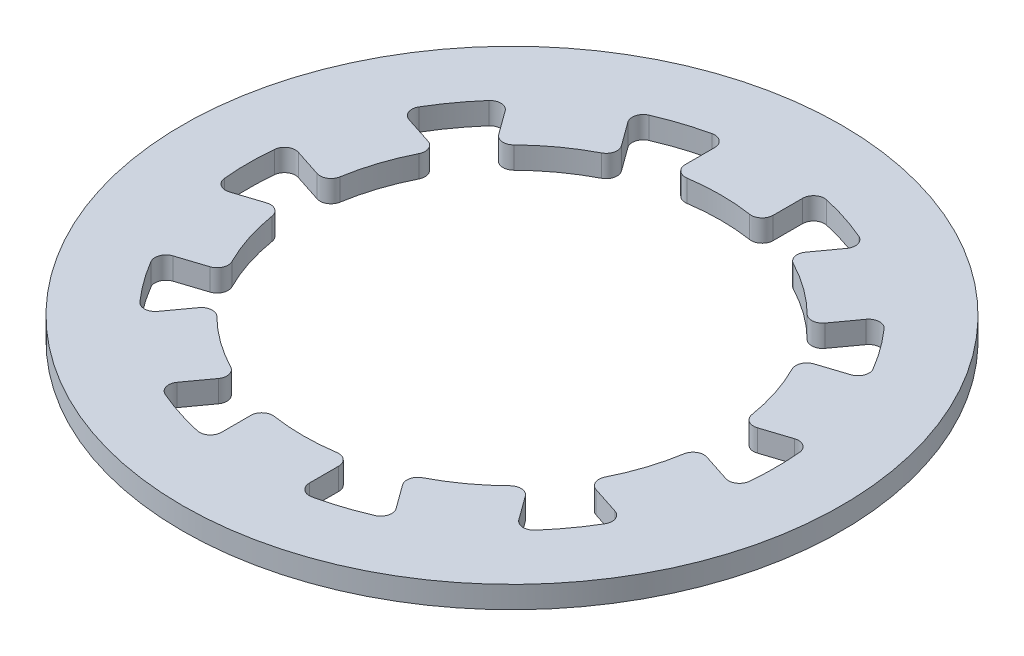
from build123d import *

# Parameters (mm, degrees)
SKETCH1_R           = 15
BOSS_EXTRUDE1_DEPTH = 1


with BuildPart() as part:
    # Sketch1 → Boss-Extrude1 (new body)
    with BuildSketch(Plane(origin=(0, 0, 0), x_dir=(1, 0, 0), z_dir=(0, 1, 0))):
        Circle(SKETCH1_R)
        with BuildLine():
            Line((-2, 11.22497216), (-2, 9.886859967))
            ThreePointArc((-2, 9.886859967), (-1.82596012, 9.507716194), (-1.425, 9.392516968))
            ThreePointArc((-1.425, 9.392516968), (0, 9.5), (1.425, 9.392516968))
            ThreePointArc((1.425, 9.392516968), (1.82596012, 9.507716194), (2, 9.886859967))
            Line((2, 9.886859967), (2, 11.22497216))
            ThreePointArc((2, 11.22497216), (2.187228379, 11.615066909), (2.608695652, 11.713014428))
            ThreePointArc((2.608695652, 11.713014428), (3.708203932, 11.412678196), (4.774258025, 11.00938056))
            ThreePointArc((4.774258025, 11.00938056), (5.057660104, 10.682407105), (4.979839104, 10.256763744))
            Line((4.979839104, 10.256763744), (4.193316491, 9.174208239))
            ThreePointArc((4.193316491, 9.174208239), (4.111262594, 8.765176409), (4.367933739, 8.436299832))
            ThreePointArc((4.367933739, 8.436299832), (5.583959897, 7.685661447), (6.673632173, 6.761111863))
            ThreePointArc((6.673632173, 6.761111863), (7.06572813, 6.618631549), (7.429384469, 6.823067229))
            Line((7.429384469, 6.823067229), (8.215907082, 7.905622735))
            ThreePointArc((8.215907082, 7.905622735), (8.596669963, 8.111165936), (8.995216257, 7.942674896))
            ThreePointArc((8.995216257, 7.942674896), (9.708203932, 7.053423028), (10.333607408, 6.100537513))
            ThreePointArc((10.333607408, 6.100537513), (10.370694331, 5.669430868), (10.05754893, 5.370820192))
            Line((10.05754893, 5.370820192), (8.784928608, 4.957320783))
            ThreePointArc((8.784928608, 4.957320783), (8.478122734, 4.674637153), (8.49246525, 4.257702899))
            ThreePointArc((8.49246525, 4.257702899), (9.035036905, 2.935661447), (9.373163684, 1.547191827))
            ThreePointArc((9.373163684, 1.547191827), (9.60662815, 1.201454611), (10.020996586, 1.153094718))
            Line((10.020996586, 1.153094718), (11.293616907, 1.566594126))
            ThreePointArc((11.293616907, 1.566594126), (11.722475811, 1.509075263), (11.945869987, 1.138503515))
            ThreePointArc((11.945869987, 1.138503515), (12, 0), (11.945869987, -1.138503515))
            ThreePointArc((11.945869987, -1.138503515), (11.722475811, -1.509075263), (11.293616907, -1.566594126))
            Line((11.293616907, -1.566594126), (10.020996586, -1.153094718))
            ThreePointArc((10.020996586, -1.153094718), (9.60662815, -1.201454611), (9.373163684, -1.547191827))
            ThreePointArc((9.373163684, -1.547191827), (9.035036905, -2.935661447), (8.49246525, -4.257702899))
            ThreePointArc((8.49246525, -4.257702899), (8.478122734, -4.674637153), (8.784928608, -4.957320783))
            Line((8.784928608, -4.957320783), (10.05754893, -5.370820192))
            ThreePointArc((10.05754893, -5.370820192), (10.370694331, -5.669430868), (10.333607408, -6.100537513))
            ThreePointArc((10.333607408, -6.100537513), (9.708203932, -7.053423028), (8.995216257, -7.942674896))
            ThreePointArc((8.995216257, -7.942674896), (8.596669963, -8.111165936), (8.215907082, -7.905622735))
            Line((8.215907082, -7.905622735), (7.429384469, -6.823067229))
            ThreePointArc((7.429384469, -6.823067229), (7.06572813, -6.618631549), (6.673632173, -6.761111863))
            ThreePointArc((6.673632173, -6.761111863), (5.583959897, -7.685661447), (4.367933739, -8.436299832))
            ThreePointArc((4.367933739, -8.436299832), (4.111262594, -8.765176409), (4.193316491, -9.174208239))
            Line((4.193316491, -9.174208239), (4.979839104, -10.256763744))
            ThreePointArc((4.979839104, -10.256763744), (5.057660104, -10.682407105), (4.774258025, -11.00938056))
            ThreePointArc((4.774258025, -11.00938056), (3.708203932, -11.412678196), (2.608695652, -11.713014428))
            ThreePointArc((2.608695652, -11.713014428), (2.187228379, -11.615066909), (2, -11.22497216))
            Line((2, -11.22497216), (2, -9.886859967))
            ThreePointArc((2, -9.886859967), (1.82596012, -9.507716194), (1.425, -9.392516968))
            ThreePointArc((1.425, -9.392516968), (0, -9.5), (-1.425, -9.392516968))
            ThreePointArc((-1.425, -9.392516968), (-1.82596012, -9.507716194), (-2, -9.886859967))
            Line((-2, -9.886859967), (-2, -11.22497216))
            ThreePointArc((-2, -11.22497216), (-2.187228379, -11.615066909), (-2.608695652, -11.713014428))
            ThreePointArc((-2.608695652, -11.713014428), (-3.708203932, -11.412678196), (-4.774258025, -11.00938056))
            ThreePointArc((-4.774258025, -11.00938056), (-5.057660104, -10.682407105), (-4.979839104, -10.256763744))
            Line((-4.979839104, -10.256763744), (-4.193316491, -9.174208239))
            ThreePointArc((-4.193316491, -9.174208239), (-4.111262594, -8.765176409), (-4.367933739, -8.436299832))
            ThreePointArc((-4.367933739, -8.436299832), (-5.583959897, -7.685661447), (-6.673632173, -6.761111863))
            ThreePointArc((-6.673632173, -6.761111863), (-7.06572813, -6.618631549), (-7.429384469, -6.823067229))
            Line((-7.429384469, -6.823067229), (-8.215907082, -7.905622735))
            ThreePointArc((-8.215907082, -7.905622735), (-8.596669963, -8.111165936), (-8.995216257, -7.942674896))
            ThreePointArc((-8.995216257, -7.942674896), (-9.708203932, -7.053423028), (-10.333607408, -6.100537513))
            ThreePointArc((-10.333607408, -6.100537513), (-10.370694331, -5.669430868), (-10.05754893, -5.370820192))
            Line((-10.05754893, -5.370820192), (-8.784928608, -4.957320783))
            ThreePointArc((-8.784928608, -4.957320783), (-8.478122734, -4.674637153), (-8.49246525, -4.257702899))
            ThreePointArc((-8.49246525, -4.257702899), (-9.035036905, -2.935661447), (-9.373163684, -1.547191827))
            ThreePointArc((-9.373163684, -1.547191827), (-9.60662815, -1.201454611), (-10.020996586, -1.153094718))
            Line((-10.020996586, -1.153094718), (-11.293616907, -1.566594126))
            ThreePointArc((-11.293616907, -1.566594126), (-11.722475811, -1.509075263), (-11.945869987, -1.138503515))
            ThreePointArc((-11.945869987, -1.138503515), (-12, 0), (-11.945869987, 1.138503515))
            ThreePointArc((-11.945869987, 1.138503515), (-11.722475811, 1.509075263), (-11.293616907, 1.566594126))
            Line((-11.293616907, 1.566594126), (-10.020996586, 1.153094718))
            ThreePointArc((-10.020996586, 1.153094718), (-9.60662815, 1.201454611), (-9.373163684, 1.547191827))
            ThreePointArc((-9.373163684, 1.547191827), (-9.035036905, 2.935661447), (-8.49246525, 4.257702899))
            ThreePointArc((-8.49246525, 4.257702899), (-8.478122734, 4.674637153), (-8.784928608, 4.957320783))
            Line((-8.784928608, 4.957320783), (-10.05754893, 5.370820192))
            ThreePointArc((-10.05754893, 5.370820192), (-10.370694331, 5.669430868), (-10.333607408, 6.100537513))
            ThreePointArc((-10.333607408, 6.100537513), (-9.708203932, 7.053423028), (-8.995216257, 7.942674896))
            ThreePointArc((-8.995216257, 7.942674896), (-8.596669963, 8.111165936), (-8.215907082, 7.905622735))
            Line((-8.215907082, 7.905622735), (-7.429384469, 6.823067229))
            ThreePointArc((-7.429384469, 6.823067229), (-7.06572813, 6.618631549), (-6.673632173, 6.761111863))
            ThreePointArc((-6.673632173, 6.761111863), (-5.583959897, 7.685661447), (-4.367933739, 8.436299832))
            ThreePointArc((-4.367933739, 8.436299832), (-4.111262594, 8.765176409), (-4.193316491, 9.174208239))
            Line((-4.193316491, 9.174208239), (-4.979839104, 10.256763744))
            ThreePointArc((-4.979839104, 10.256763744), (-5.057660104, 10.682407105), (-4.774258025, 11.00938056))
            ThreePointArc((-4.774258025, 11.00938056), (-3.708203932, 11.412678196), (-2.608695652, 11.713014428))
            ThreePointArc((-2.608695652, 11.713014428), (-2.187228379, 11.615066909), (-2, 11.22497216))
        make_face(mode=Mode.SUBTRACT)
    extrude(amount=BOSS_EXTRUDE1_DEPTH)


solid = part.part
